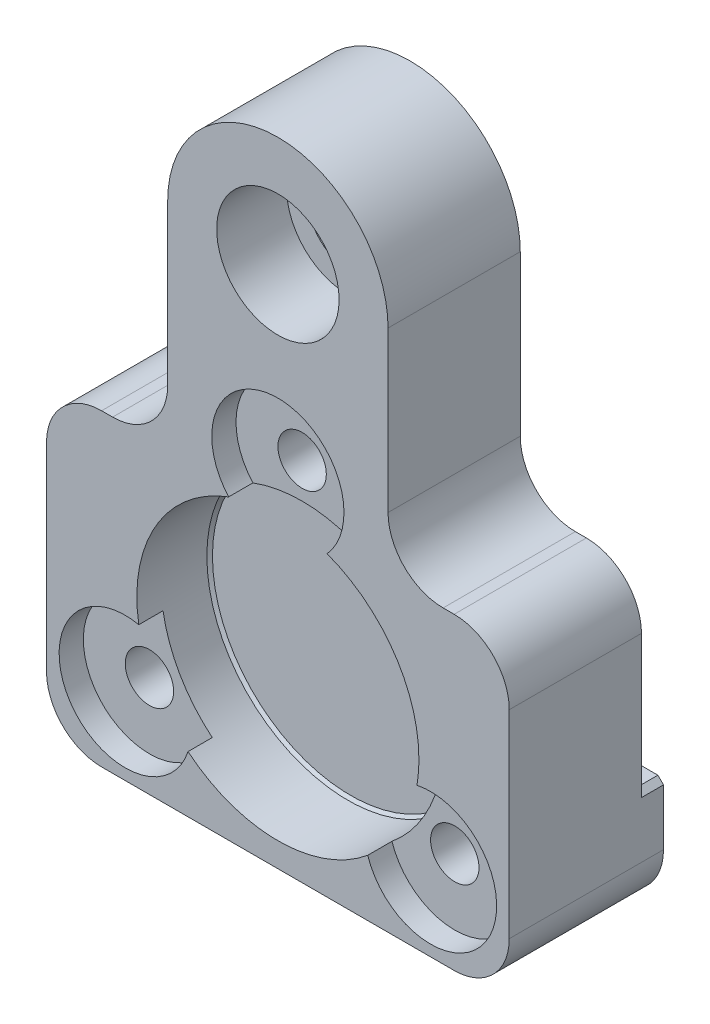
from build123d import *

# Parameters (mm, degrees)
BOSS_EXTRUDE1_DEPTH                              = 14
SKETCH2_R                                        = 12.8
CUT_EXTRUDE1_DEPTH                               = 6.608
CBORE_FOR_1_4_SOCKET_HEAD_CAP_SCREW1_D           = 7.14248
CBORE_FOR_1_4_SOCKET_HEAD_CAP_SCREW1_CBORE_D     = 11.1125
CBORE_FOR_1_4_SOCKET_HEAD_CAP_SCREW1_CBORE_DEPTH = 6.35
SKETCH5_R                                        = 6
CUT_EXTRUDE2_DEPTH                               = 2.2
CIRPATTERN2_COUNT                                = 3
TAPPED_HOLE_FOR_8_32_HELICOIL1_D                 = 4.3942
TAPPED_HOLE_FOR_8_32_HELICOIL1_DEPTH             = 13.322
TAPPED_HOLE_FOR_8_32_HELICOIL1_TIP               = 1.320150866
SKETCH8_W                                        = 42
SKETCH8_H                                        = 46.9
CUT_EXTRUDE3_DEPTH                               = 2
CHAMFER1_SIZE                                    = 0.508
CHAMFER2_SIZE                                    = 0.254


with BuildPart() as part:
    # Sketch1 → Boss-Extrude1 (new body)
    with BuildSketch(Plane.XY):
        with BuildLine():
            Line((-10, 18), (-10, 32.5))
            ThreePointArc((-10, 32.5), (0, 42.5), (10, 32.5))
            Line((10, 32.5), (10, 18))
            ThreePointArc((10, 18), (11.464466094, 14.464466094), (15, 13))
            Line((15, 13), (16, 13))
            ThreePointArc((16, 13), (19.535533906, 11.535533906), (21, 8))
            Line((21, 8), (21, -10))
            ThreePointArc((21, -10), (19.535533906, -13.535533906), (16, -15))
            Line((16, -15), (-16, -15))
            ThreePointArc((-16, -15), (-19.535533906, -13.535533906), (-21, -10))
            Line((-21, -10), (-21, 8))
            ThreePointArc((-21, 8), (-19.535533906, 11.535533906), (-16, 13))
            Line((-16, 13), (-15, 13))
            ThreePointArc((-15, 13), (-11.464466094, 14.464466094), (-10, 18))
        make_face()
    extrude(amount=BOSS_EXTRUDE1_DEPTH)

    # Sketch2 → Cut-Extrude1 (cut)
    with BuildSketch(Plane.XY.offset(14)):
        Circle(SKETCH2_R)
    extrude(amount=-CUT_EXTRUDE1_DEPTH, mode=Mode.SUBTRACT)

    # CBORE for 1_4 Socket Head Cap Screw1 (through all)
    with Locations(Plane.XY.offset(14)):
        with Locations((0, 32.5)):
            CounterBoreHole(CBORE_FOR_1_4_SOCKET_HEAD_CAP_SCREW1_D / 2, CBORE_FOR_1_4_SOCKET_HEAD_CAP_SCREW1_CBORE_D / 2, CBORE_FOR_1_4_SOCKET_HEAD_CAP_SCREW1_CBORE_DEPTH)

    # Sketch5 → Cut-Extrude2 (cut)
    with BuildSketch(Plane.XY.offset(14)):
        with Locations((0, 16)):
            Circle(SKETCH5_R)
    cut_extrude2 = extrude(amount=-CUT_EXTRUDE2_DEPTH, mode=Mode.SUBTRACT)

    # CirPattern2: Cut-Extrude2 ×3 about axis
    cirpattern2_axis = Axis((0, 0, 0), (0, 0, 1))
    for i in range(1, CIRPATTERN2_COUNT):
        add(cut_extrude2.rotate(cirpattern2_axis, i * 360 / CIRPATTERN2_COUNT), mode=Mode.SUBTRACT)

    # Tapped Hole for _8-32 Helicoil1
    with Locations(Plane.XY.offset(11.8)):
        with Locations((0, 16), (-13.856406461, -8), (13.856406461, -8)):
            Hole(TAPPED_HOLE_FOR_8_32_HELICOIL1_D / 2, depth=TAPPED_HOLE_FOR_8_32_HELICOIL1_DEPTH)
            with Locations((0, 0, -(TAPPED_HOLE_FOR_8_32_HELICOIL1_DEPTH + TAPPED_HOLE_FOR_8_32_HELICOIL1_TIP / 2))):  # 118° drill point
                Cone(0, TAPPED_HOLE_FOR_8_32_HELICOIL1_D / 2, TAPPED_HOLE_FOR_8_32_HELICOIL1_TIP, mode=Mode.SUBTRACT)

    # Sketch8 → Cut-Extrude3 (cut)
    with BuildSketch(Plane(origin=(0, 0, 0), x_dir=(-1, 0, 0), z_dir=(0, 0, -1))):
        with Locations((0, 19.05)):
            Rectangle(SKETCH8_W, SKETCH8_H)
    extrude(amount=-CUT_EXTRUDE3_DEPTH, mode=Mode.SUBTRACT)

    # Chamfer1
    chamfer1_edges = [part.edges().sort_by_distance(p)[0] for p in [
        (21, -4.4, 1),
        (-21, -4.4, 1),
    ]]
    chamfer(chamfer1_edges, length=CHAMFER1_SIZE)

    # Chamfer2
    chamfer2_edges = [part.edges().sort_by_distance(p)[0] for p in [
        (-12.8, 0, 7.392),
    ]]
    chamfer(chamfer2_edges, length=CHAMFER2_SIZE)


solid = part.part
